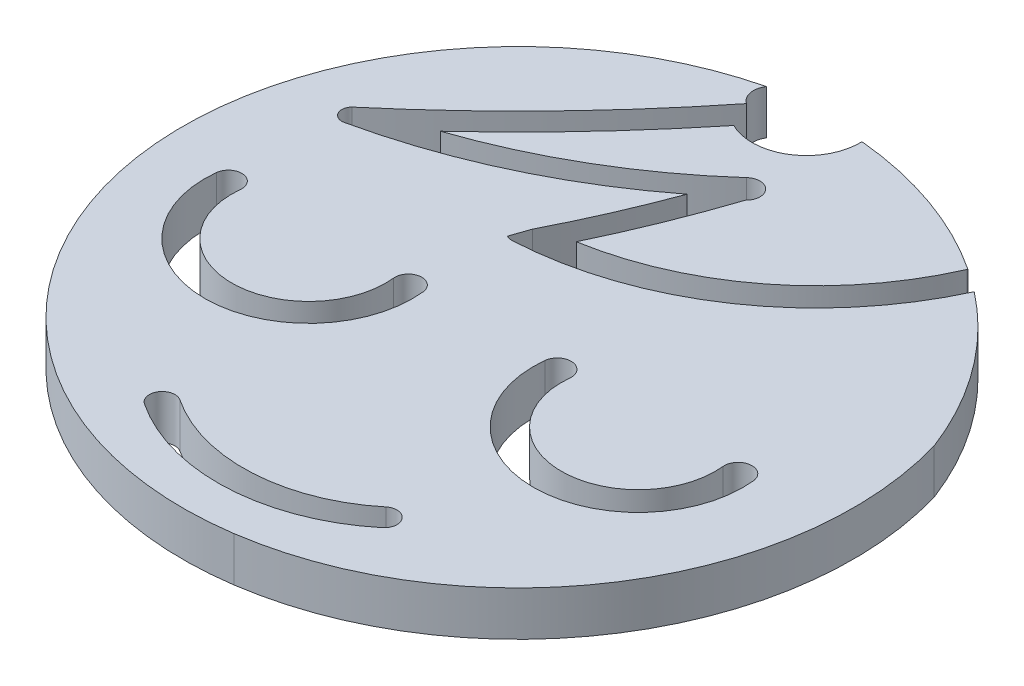
from build123d import *

# Parameters (mm, degrees)
SALIENTE_EXTRUIR1_DEPTH   = 3
SALIENTE_EXTRUIR1_2_DEPTH = 3


with BuildPart() as part:
    # Croquis1 → Saliente-Extruir1 (new body)
    with BuildSketch(Plane(origin=(0, 0, 0), x_dir=(1, 0, 0), z_dir=(0, 1, 0))):
        with BuildLine():
            Line((45.425593016, 39.206344036), (44.993103459, 37.95333726))
            ThreePointArc((44.993103459, 37.95333726), (45.217239696, 37.87538969), (45.453858509, 37.857378194))
            ThreePointArc((45.453858509, 37.857378194), (56.466858378, 41.570973662), (63.970806845, 50.446091398))
            ThreePointArc((63.970806845, 50.446091398), (68.49783746, 45.799067947), (71.613505946, 40.108598457))
            ThreePointArc((71.613505946, 40.108598457), (68.920422337, 21.532290532), (53.136426633, 11.373678664))
            ThreePointArc((53.136426633, 11.373678664), (32.960940305, 18.979259272), (28.666044434, 40.108598457))
            ThreePointArc((28.666044434, 40.108598457), (34.821076063, 49.9061201), (44.993103459, 55.420256783))
            ThreePointArc((44.993103459, 55.420256783), (44.807683463, 54.519820522), (45.313276313, 53.7520042))
            ThreePointArc((45.313276313, 53.7520042), (39.105711287, 46.680393607), (32.227179127, 40.259542009))
            ThreePointArc((32.227179127, 40.259542009), (32.106258057, 39.428878951), (32.878756679, 39.10044494))
            ThreePointArc((32.878756679, 39.10044494), (41.148364583, 41.902874928), (48.597651163, 46.457889546))
            ThreePointArc((48.597651163, 46.457889546), (47.118213116, 42.785490463), (45.425593016, 39.206344036))
        make_face()
        with BuildLine():
            ThreePointArc((31.471767073, 31.862125217), (38.438273667, 24.114134575), (45.404780261, 31.862125217))
            ThreePointArc((45.404780261, 31.862125217), (44.409089735, 32.666113812), (43.60510114, 31.670423286))
            ThreePointArc((43.60510114, 31.670423286), (38.438273667, 25.923994948), (33.271446194, 31.670423286))
            ThreePointArc((33.271446194, 31.670423286), (32.467457599, 32.666113812), (31.471767073, 31.862125217))
        make_face(mode=Mode.SUBTRACT)
        with BuildLine():
            ThreePointArc((53.513579106, 31.958619171), (60.542287348, 24.166307285), (67.570995591, 31.958619171))
            ThreePointArc((67.570995591, 31.958619171), (66.540546849, 32.796080004), (65.703086016, 31.765631263))
            ThreePointArc((65.703086016, 31.765631263), (60.542287348, 26.044159919), (55.381488681, 31.765631263))
            ThreePointArc((55.381488681, 31.765631263), (54.544027848, 32.796080004), (53.513579106, 31.958619171))
        make_face(mode=Mode.SUBTRACT)
        with BuildLine():
            ThreePointArc((42.556430807, 15.924022523), (50.311008053, 13.805956585), (57.801408595, 16.723759063))
            ThreePointArc((57.801408595, 16.723759063), (57.916842518, 17.936511186), (56.704090395, 18.051945109))
            ThreePointArc((56.704090395, 18.051945109), (50.220753546, 15.526433126), (43.508757823, 17.359730941))
            ThreePointArc((43.508757823, 17.359730941), (42.314740106, 17.11804024), (42.556430807, 15.924022523))
        make_face(mode=Mode.SUBTRACT)
    extrude(amount=SALIENTE_EXTRUIR1_DEPTH)


with BuildPart() as body_2:
    # Croquis1 → Saliente-Extruir1 2 (new body)
    with BuildSketch(Plane(origin=(0, 0, 0), x_dir=(1, 0, 0), z_dir=(0, 1, 0))):
        with BuildLine():
            ThreePointArc((47.640867648, 39.950179711), (56.485714844, 43.860153446), (62.42425572, 51.492515388))
            ThreePointArc((62.42425572, 51.492515388), (62.435630847, 51.517356792), (62.447738759, 51.54184939))
            ThreePointArc((62.447738759, 51.54184939), (57.180344633, 54.161726438), (51.4335805, 55.420256783))
            ThreePointArc((51.4335805, 55.420256783), (49.75419333, 52.240495167), (46.163596362, 52.043420018))
            ThreePointArc((46.163596362, 52.043420018), (41.569805001, 46.757329696), (36.604580424, 41.818482171))
            ThreePointArc((36.604580424, 41.818482171), (43.508384082, 44.970402926), (49.642890368, 49.43861756))
            ThreePointArc((49.642890368, 49.43861756), (50.962800398, 49.394169945), (50.918352783, 48.074259915))
            ThreePointArc((50.918352783, 48.074259915), (49.408626903, 43.96017081), (47.640867648, 39.950179711))
        make_face()
    extrude(amount=SALIENTE_EXTRUIR1_2_DEPTH)


solid = Compound([part.part, body_2.part])
